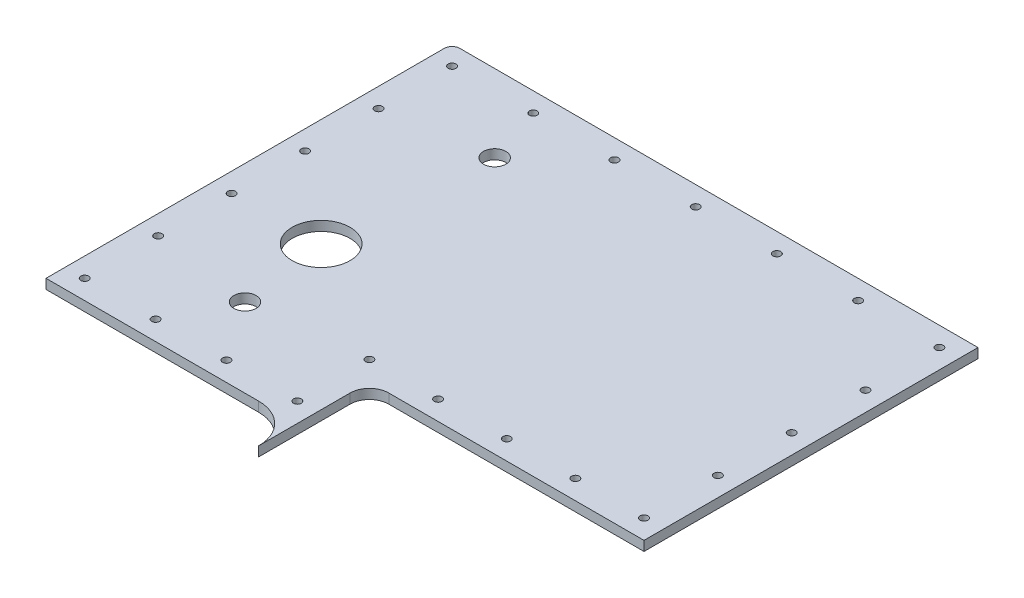
from build123d import *

# Parameters (mm, degrees)
BOSS_EXTRUDE1_DEPTH     = 1.5875
FILLET1_R               = 3.175
SKETCH2_R               = 4.750027573
SKETCH2_R_2             = 1.830008083
CUT_EXTRUDE1_DEPTH      = 1
CUT_EXTRUDE1_DEPTH_BACK = 2.5875
SKETCH3_R               = 0.635
CUT_EXTRUDE2_DEPTH      = 1
CUT_EXTRUDE2_DEPTH_BACK = 2.5875


with BuildPart() as part:
    # Sketch1 → Boss-Extrude1 (new body)
    with BuildSketch(Plane(origin=(0, 0, 0), x_dir=(1, 0, 0), z_dir=(0, 1, 0))):
        with BuildLine():
            Line((-8.89, -66.675), (-43.815, -66.675))
            Line((-43.815, -66.675), (-43.815, -1.27))
            ThreePointArc((-43.815, -1.27), (-43.443025612, -0.371974388), (-42.545, 0))
            Line((-42.545, 0), (42.545, 0))
            Line((42.545, 0), (42.545, -54.843091388))
            Line((42.545, -54.843091388), (-2.54, -54.843091388))
            Line((-2.54, -54.843091388), (-2.54, -73.025))
            ThreePointArc((-2.54, -73.025), (-4.399871939, -68.534871939), (-8.89, -66.675))
        make_face()
    extrude(amount=BOSS_EXTRUDE1_DEPTH)

    # Fillet1
    fillet1_edges = [part.edges().sort_by_distance(p)[0] for p in [
        (-2.54, 0.79375, 54.843091388),
    ]]
    fillet(fillet1_edges, radius=FILLET1_R)

    # Sketch2 → Cut-Extrude1 (cut, two sides)
    with BuildSketch(Plane(origin=(0, 1.5875, 0), x_dir=(-1, 0, 0), z_dir=(0, 1, 0))) as cut_extrude1_sk:
        with Locations((26.115028378, 39.200331632)):
            Circle(SKETCH2_R)
        with Locations((24.115016768, 53.700415803)):
            Circle(SKETCH2_R_2)
        with Locations((24.114889767, 12.7)):
            Circle(SKETCH2_R_2)
    extrude(amount=CUT_EXTRUDE1_DEPTH, mode=Mode.SUBTRACT)
    extrude(cut_extrude1_sk.sketch, amount=-CUT_EXTRUDE1_DEPTH_BACK, mode=Mode.SUBTRACT)

    # Sketch3 → Cut-Extrude2 (cut, two sides)
    with BuildSketch(Plane(origin=(0, 1.5875, 0), x_dir=(-1, 0, 0), z_dir=(0, 1, 0))) as cut_extrude2_sk:
        with Locations((27.305, 3.175)):
            Circle(SKETCH3_R)
        with Locations((13.97, 3.175)):
            Circle(SKETCH3_R)
        with Locations((0.635, 3.175)):
            Circle(SKETCH3_R)
        with Locations((-12.7, 3.175)):
            Circle(SKETCH3_R)
        with Locations((-26.035, 3.175)):
            Circle(SKETCH3_R)
        with Locations((-39.37, 3.175)):
            Circle(SKETCH3_R)
        with Locations((-39.37, 15.298272847)):
            Circle(SKETCH3_R)
        with Locations((-39.37, 27.421545694)):
            Circle(SKETCH3_R)
        with Locations((-39.37, 39.544818541)):
            Circle(SKETCH3_R)
        with Locations((-39.37, 51.668091388)):
            Circle(SKETCH3_R)
        with Locations((-28.09875, 51.668091388)):
            Circle(SKETCH3_R)
        with Locations((-16.8275, 51.668091388)):
            Circle(SKETCH3_R)
        with Locations((-5.55625, 51.668091388)):
            Circle(SKETCH3_R)
        with Locations((5.715, 51.668091388)):
            Circle(SKETCH3_R)
        with Locations((5.715, 63.5)):
            Circle(SKETCH3_R)
        with Locations((17.356666667, 63.5)):
            Circle(SKETCH3_R)
        with Locations((28.998333333, 63.5)):
            Circle(SKETCH3_R)
        with Locations((40.64, 63.5)):
            Circle(SKETCH3_R)
        with Locations((40.64, 51.435)):
            Circle(SKETCH3_R)
        with Locations((40.64, 39.37)):
            Circle(SKETCH3_R)
        with Locations((40.64, 27.305)):
            Circle(SKETCH3_R)
        with Locations((40.64, 15.24)):
            Circle(SKETCH3_R)
        with Locations((40.64, 3.175)):
            Circle(SKETCH3_R)
    extrude(amount=CUT_EXTRUDE2_DEPTH, mode=Mode.SUBTRACT)
    extrude(cut_extrude2_sk.sketch, amount=-CUT_EXTRUDE2_DEPTH_BACK, mode=Mode.SUBTRACT)


solid = part.part
